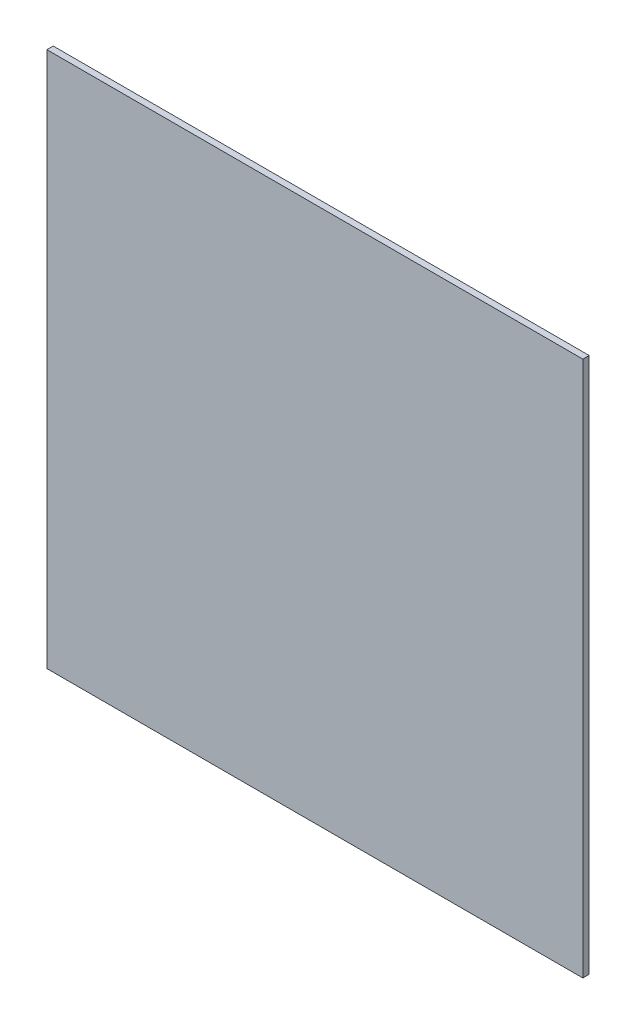
from build123d import *

# Parameters (mm, degrees)
SKETCH1_W           = 254
SKETCH1_H           = 254
BOSS_EXTRUDE1_DEPTH = 3


with BuildPart() as part:
    # Sketch1 → Boss-Extrude1 (new body)
    with BuildSketch(Plane.XY.offset(3)):
        Rectangle(SKETCH1_W, SKETCH1_H)
    extrude(amount=-BOSS_EXTRUDE1_DEPTH)


solid = part.part
